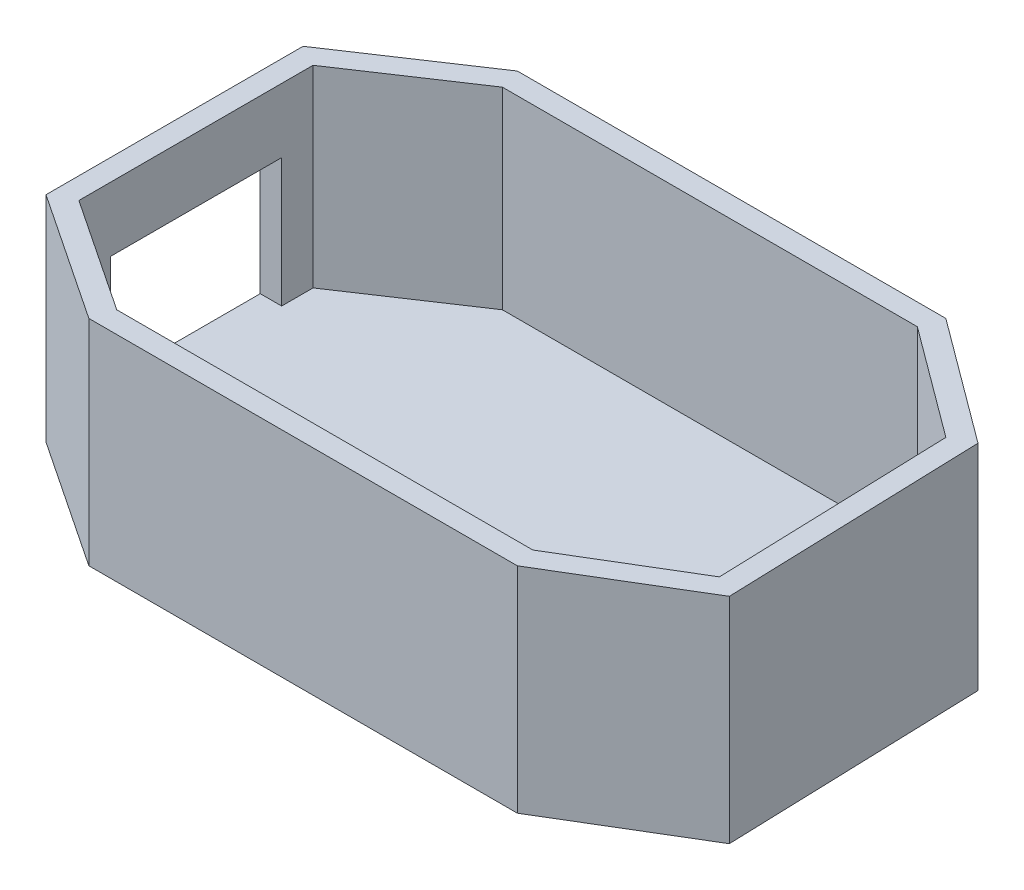
from build123d import *

# Parameters (mm, degrees)
DODANIE_WYCI_GNI_CIE2_DEPTH = 50
SKORUPA2_T                  = -5
WYTNIJ_WYCI_GNI_CIE1_REACH  = 162.907
SZKIC2_W                    = 40
SZKIC2_H                    = 30


with BuildPart() as part:
    # Szkic1 → Dodanie-wyciągnięcie2 (new body)
    with BuildSketch(Plane(origin=(0, 0, 0), x_dir=(1, 0, 0), z_dir=(0, 1, 0))):
        Polygon((-60, 40), (40, 40), (68.970961298, 18.536463444), (70.906962059, -41.432294264), (40, -60), (-60, -60), (-90, -40), (-90, 20), align=None)
    extrude(amount=DODANIE_WYCI_GNI_CIE2_DEPTH)

    # Skorupa2
    skorupa2_openings = [part.faces().sort_by_distance(p)[0] for p in [
        (-10.01525958, 50, 10.361978853),
    ]]
    offset(amount=SKORUPA2_T, openings=skorupa2_openings, kind=Kind.INTERSECTION)

    # Szkic2 → Wytnij-wyciągnięcie1 (cut, up to next)
    with BuildSketch(Plane.ZY.offset(90), mode=Mode.PRIVATE) as wytnij_wyci_gni_cie1_sk1:
        with Locations((10, 20)):
            Rectangle(SZKIC2_W, SZKIC2_H)
    wytnij_wyci_gni_cie1_tool1 = extrude(wytnij_wyci_gni_cie1_sk1.sketch, amount=-WYTNIJ_WYCI_GNI_CIE1_REACH, mode=Mode.PRIVATE) & part.part
    add(wytnij_wyci_gni_cie1_tool1.solids().sort_by_distance((-90, 20, 10))[0], mode=Mode.SUBTRACT)


solid = part.part
